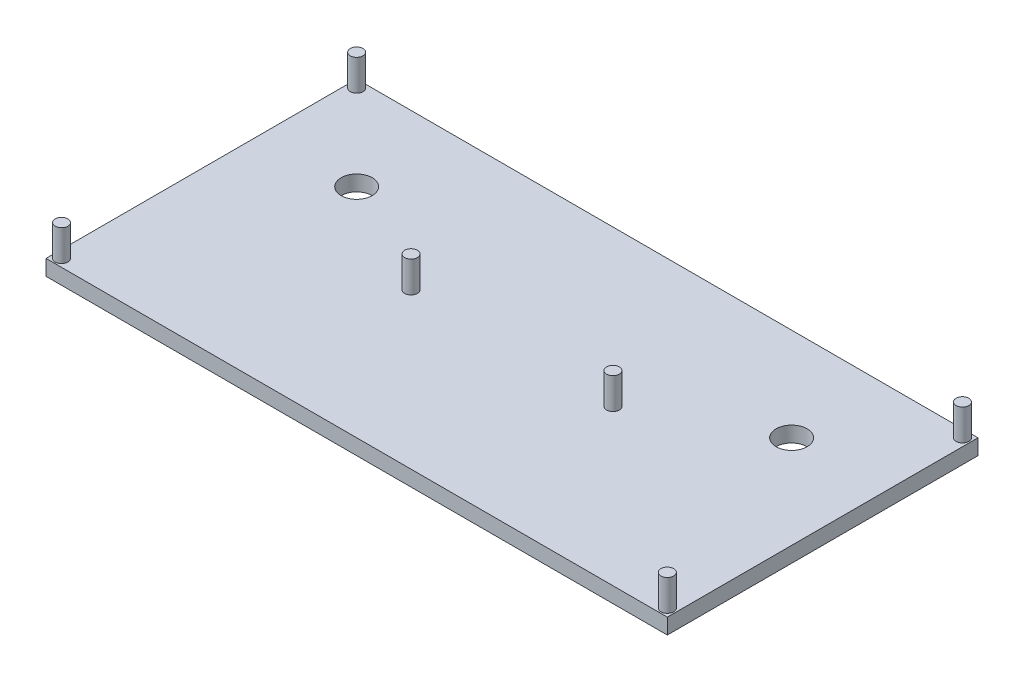
from build123d import *

# Parameters (mm, degrees)
SKETCH1_W           = 200
SKETCH1_H           = 100
BOSS_EXTRUDE1_DEPTH = 5
SKETCH2_R           = 2.05
BOSS_EXTRUDE2_DEPTH = 10
SKETCH3_R           = 5
CUT_EXTRUDE1_DEPTH  = 10


with BuildPart() as part:
    # Sketch1 → Boss-Extrude1 (new body)
    with BuildSketch(Plane(origin=(0, 0, 0), x_dir=(1, 0, 0), z_dir=(0, 1, 0))):
        with Locations((100, 50)):
            Rectangle(SKETCH1_W, SKETCH1_H)
    extrude(amount=BOSS_EXTRUDE1_DEPTH)

    # Sketch2 → Boss-Extrude2 (add)
    with BuildSketch(Plane(origin=(0, 5, 0), x_dir=(1, 0, 0), z_dir=(0, 1, 0))):
        with Locations((2.5, 97.5)):
            Circle(SKETCH2_R)
        with Locations((197.5, 97.5)):
            Circle(SKETCH2_R)
        with Locations((197.5, 2.5)):
            Circle(SKETCH2_R)
        with Locations((2.5, 2.5)):
            Circle(SKETCH2_R)
        with Locations((67.5, 50)):
            Circle(SKETCH2_R)
        with Locations((132.5, 50)):
            Circle(SKETCH2_R)
    extrude(amount=BOSS_EXTRUDE2_DEPTH)

    # Sketch3 → Cut-Extrude1 (cut)
    with BuildSketch(Plane(origin=(0, 0, 0), x_dir=(-1, 0, 0), z_dir=(0, -1, 0))):
        with Locations((-170, 70)):
            Circle(SKETCH3_R)
        with Locations((-30, 70)):
            Circle(SKETCH3_R)
    extrude(amount=-CUT_EXTRUDE1_DEPTH, mode=Mode.SUBTRACT)


solid = part.part
